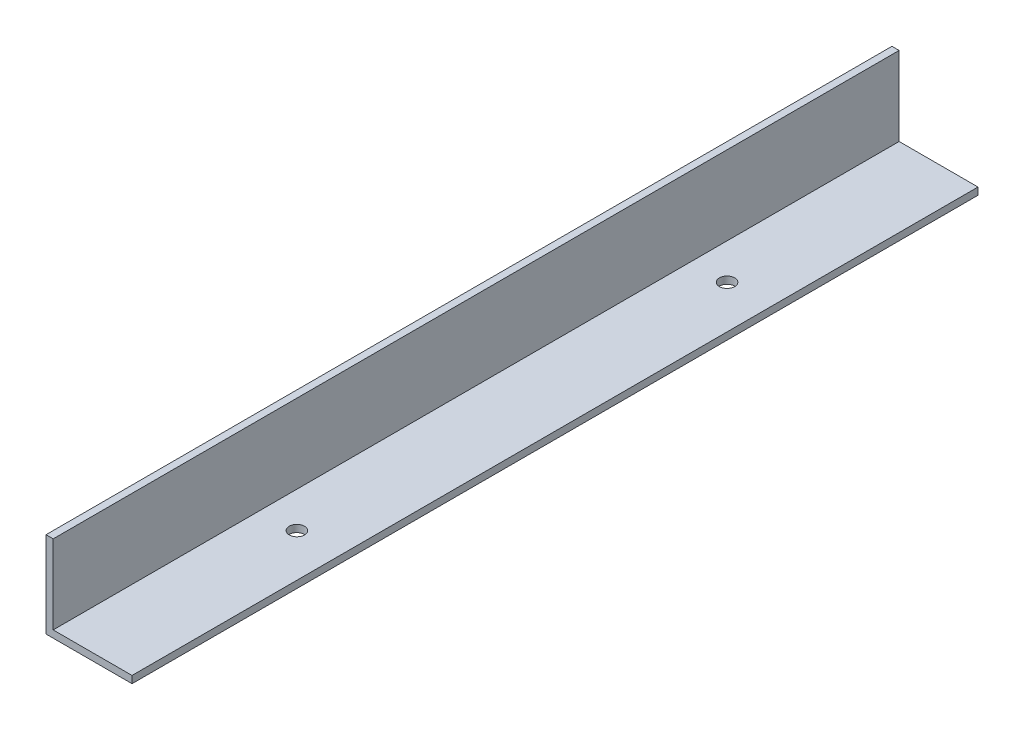
from build123d import *

# Parameters (mm, degrees)
BOSS_EXTRUDE1_DEPTH     = 374.65
F_1_4_CLEARANCE_HOLE1_D = 6.7564


with BuildPart() as part:
    # Sketch1 → Boss-Extrude1 (new body)
    with BuildSketch(Plane.XY):
        Polygon((0, 0), (0, 38.1), (3.175, 38.1), (3.175, 3.175), (38.1, 3.175), (38.1, 0), align=None)
    extrude(amount=BOSS_EXTRUDE1_DEPTH)

    # 1/4 Clearance Hole1 (through all)
    with Locations(Plane(origin=(0, 0, 0), x_dir=(-1, 0, 0), z_dir=(0, -1, 0))):
        with Locations((-19.05, -92.075), (-19.05, -282.575)):
            Hole(F_1_4_CLEARANCE_HOLE1_D / 2)


solid = part.part
